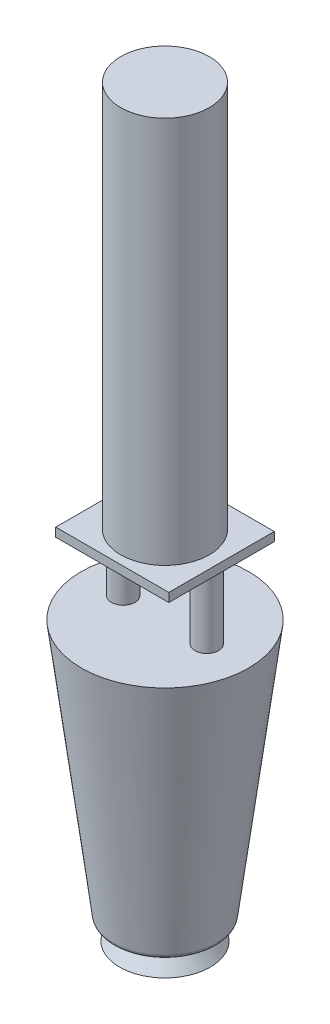
from build123d import *

# Parameters (mm, degrees)
FILLET3_R           = 1
SKETCH2_W           = 2.6733627
SKETCH2_H           = 15.8
SKETCH4_W           = 25.690547406
SKETCH4_H           = 23.95860039
BOSS_EXTRUDE1_DEPTH = 2
SKETCH5_W           = 10.057084603
SKETCH5_H           = 88


with BuildPart() as part:
    # Sketch1 → Revolve1 (revolve)
    with BuildSketch(Plane.XY):
        Polygon((0, 0), (0, 63.2), (19, 63.2), (11.588395286, 4.555292852), (6.627531845, 4.555292852), (10.308172463, 0), align=None)
    revolve(axis=Axis((0, 0, 0), (0, 1, 0)))

    # Fillet3
    fillet3_edges = [part.edges().sort_by_distance(p)[0] for p in [
        (-11.588395286, 4.555292852, 0),
    ]]
    fillet(fillet3_edges, radius=FILLET3_R)

    # Sketch2 → Revolve2 (revolve)
    with BuildSketch(Plane.XY):
        with Locations((10.825435474, 71.1)):
            Rectangle(SKETCH2_W, SKETCH2_H)
    revolve2 = revolve(axis=Axis((9.488754124, 63.2, 0), (0, 1, 0)))

    # Mirror1: Revolve2 across plane
    add(revolve2.mirror(Plane(origin=(0, 0, 0), x_dir=(0, 0, 1), z_dir=(1, 0, 0))))

    # Sketch4 → Boss-Extrude1 (add)
    with BuildSketch(Plane(origin=(0, 79, 0), x_dir=(1, 0, 0), z_dir=(0, 1, 0))):
        Rectangle(SKETCH4_W, SKETCH4_H)
    extrude(amount=BOSS_EXTRUDE1_DEPTH)

    # Sketch5 → Revolve4 (revolve)
    with BuildSketch(Plane.XY):
        with Locations((5.028542301, 125)):
            Rectangle(SKETCH5_W, SKETCH5_H)
    revolve(axis=Axis((0, 81, 0), (0, 1, 0)))


solid = part.part
